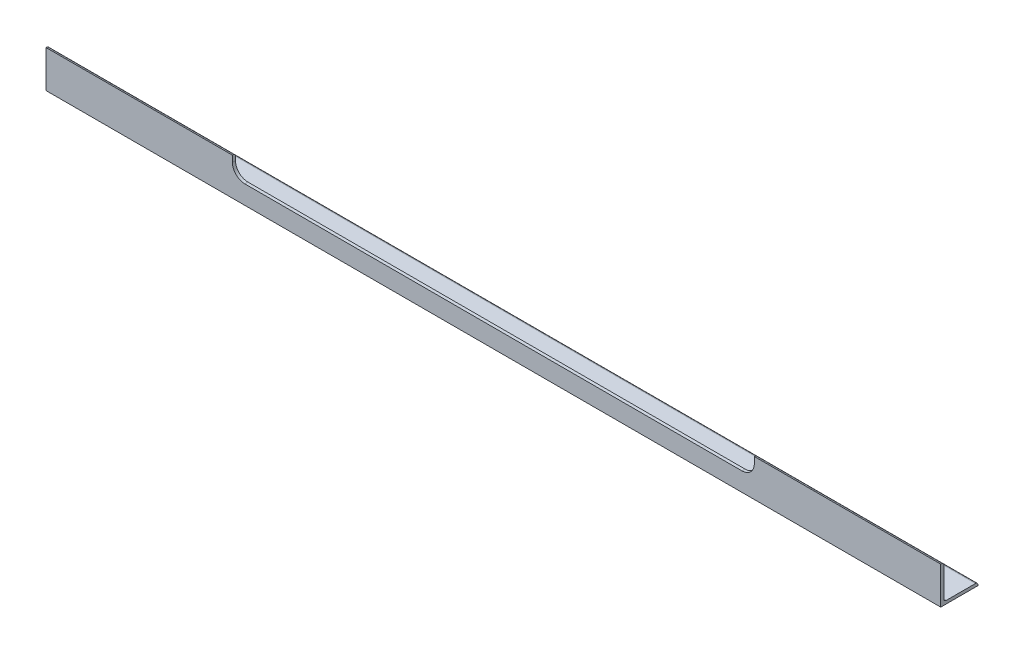
from build123d import *

# Parameters (mm, degrees)
BOSS_EXTRUDE1_DEPTH      = 914.4
BOSS_EXTRUDE1_DEPTH_BACK = 914.4
SKETCH2_W                = 1066.8
SKETCH2_H                = 38.1
CUT_EXTRUDE1_DEPTH       = 77.2
FILLET1_R                = 25.4


with BuildPart() as part:
    # Sketch1 → Boss-Extrude1 (new body, two sides)
    with BuildSketch(Plane(origin=(0, 0, 0), x_dir=(0, 0, -1), z_dir=(1, 0, 0))) as boss_extrude1_sk:
        with BuildLine():
            Line((0, 76.2), (0, 0))
            Line((0, 0), (76.2, 0))
            Line((76.2, 0), (76.2, 1.27))
            ThreePointArc((76.2, 1.27), (74.712102448, 4.862102448), (71.12, 6.35))
            Line((71.12, 6.35), (11.43, 6.35))
            ThreePointArc((11.43, 6.35), (7.837897552, 7.837897552), (6.35, 11.43))
            Line((6.35, 11.43), (6.35, 71.12))
            ThreePointArc((6.35, 71.12), (4.862102448, 74.712102448), (1.27, 76.2))
            Line((1.27, 76.2), (0, 76.2))
        make_face()
    extrude(amount=BOSS_EXTRUDE1_DEPTH)
    extrude(boss_extrude1_sk.sketch, amount=-BOSS_EXTRUDE1_DEPTH_BACK)

    # Sketch2 → Cut-Extrude1 (cut, through all)
    with BuildSketch(Plane.XY):
        with Locations((0, 57.15)):
            Rectangle(SKETCH2_W, SKETCH2_H)
    extrude(amount=-CUT_EXTRUDE1_DEPTH, mode=Mode.SUBTRACT)

    # Fillet1
    fillet1_edges = [part.edges().sort_by_distance(p)[0] for p in [
        (-533.4, 38.1, -3.175),
        (533.4, 38.1, -3.175),
    ]]
    fillet(fillet1_edges, radius=FILLET1_R)


solid = part.part
